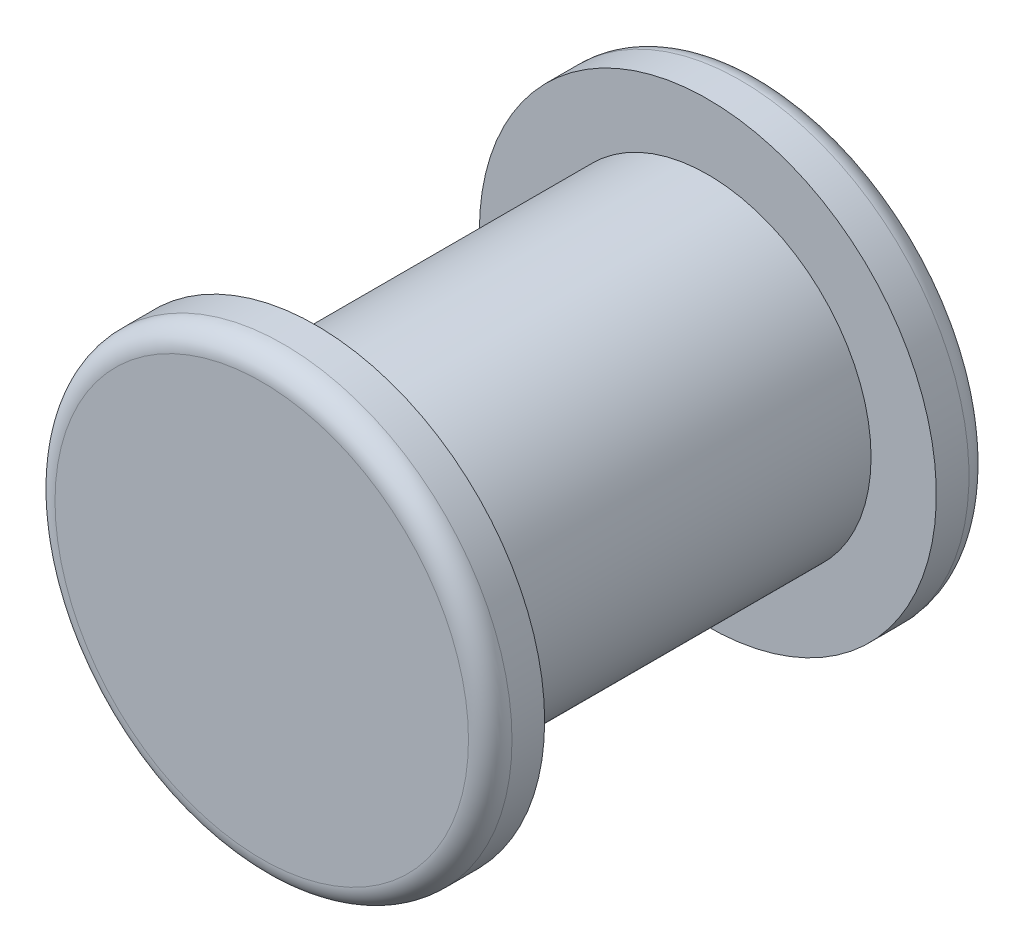
from build123d import *

# Parameters (mm, degrees)
SKETCH1_R           = 75
BOSS_EXTRUDE1_DEPTH = 180
SKETCH2_R           = 105
BOSS_EXTRUDE2_DEPTH = 25
SKETCH3_R           = 105
BOSS_EXTRUDE3_DEPTH = 25
FILLET1_R           = 10


with BuildPart() as part:
    # Sketch1 → Boss-Extrude1 (new body)
    with BuildSketch(Plane.XY):
        Circle(SKETCH1_R)
    extrude(amount=BOSS_EXTRUDE1_DEPTH)

    # Sketch2 → Boss-Extrude2 (add)
    with BuildSketch(Plane.XY.offset(180)):
        Circle(SKETCH2_R)
    extrude(amount=BOSS_EXTRUDE2_DEPTH)

    # Sketch3 → Boss-Extrude3 (add)
    with BuildSketch(Plane(origin=(0, 0, 0), x_dir=(-1, 0, 0), z_dir=(0, 0, -1))):
        Circle(SKETCH3_R)
    extrude(amount=BOSS_EXTRUDE3_DEPTH)

    # Fillet1
    fillet1_edges = [part.edges().sort_by_distance(p)[0] for p in [
        (105, 0, -25),
        (-105, 0, 205),
    ]]
    fillet(fillet1_edges, radius=FILLET1_R)


solid = part.part
